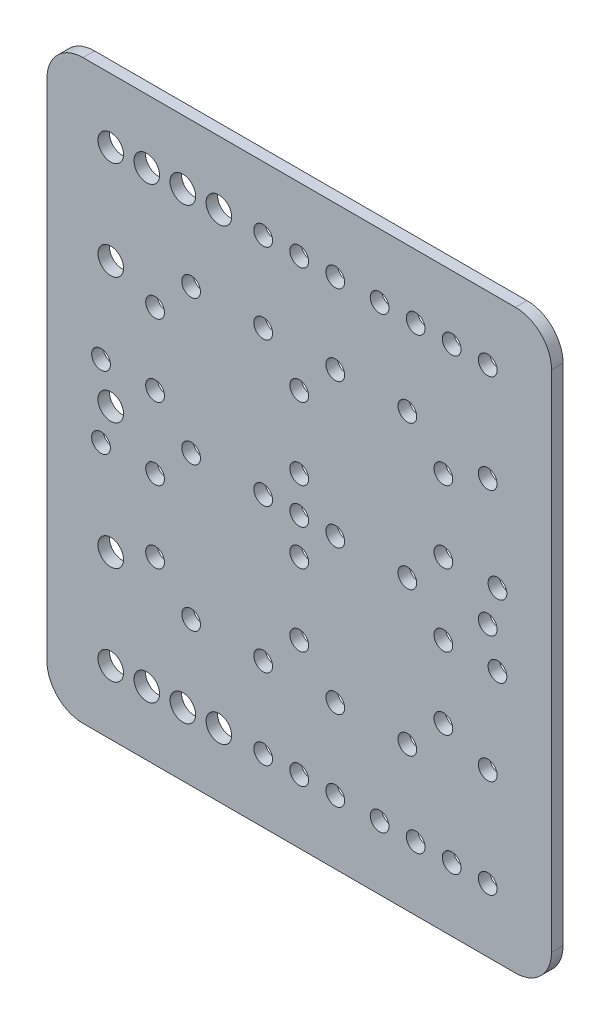
from build123d import *

# Parameters (mm, degrees)
SKETCH1_W           = 140
SKETCH1_H           = 160
SKETCH1_R           = 2.6
SKETCH1_R_2         = 3.55
BOSS_EXTRUDE1_DEPTH = 3.2
FILLET1_R           = 10


with BuildPart() as part:
    # Sketch1 → Boss-Extrude1 (new body)
    with BuildSketch(Plane.XY):
        Rectangle(SKETCH1_W, SKETCH1_H)
        Circle(SKETCH1_R, mode=Mode.SUBTRACT)
        with Locations((10, 0)):
            Circle(SKETCH1_R, mode=Mode.SUBTRACT)
        with Locations((-40, 10)):
            Circle(SKETCH1_R, mode=Mode.SUBTRACT)
        with Locations((30, 0)):
            Circle(SKETCH1_R, mode=Mode.SUBTRACT)
        with Locations((-10, 0)):
            Circle(SKETCH1_R, mode=Mode.SUBTRACT)
        with Locations((40, 10)):
            Circle(SKETCH1_R, mode=Mode.SUBTRACT)
        with Locations((-30, 0)):
            Circle(SKETCH1_R, mode=Mode.SUBTRACT)
        with Locations((0, 10)):
            Circle(SKETCH1_R, mode=Mode.SUBTRACT)
        with Locations((-52.3, 35)):
            Circle(SKETCH1_R_2, mode=Mode.SUBTRACT)
        with Locations((52.3, 35)):
            Circle(SKETCH1_R, mode=Mode.SUBTRACT)
        with Locations((22.3, 62.3)):
            Circle(SKETCH1_R, mode=Mode.SUBTRACT)
        with Locations((0, 30)):
            Circle(SKETCH1_R, mode=Mode.SUBTRACT)
        with Locations((-10, 40)):
            Circle(SKETCH1_R, mode=Mode.SUBTRACT)
        with Locations((52.3, 0)):
            Circle(SKETCH1_R, mode=Mode.SUBTRACT)
        with Locations((-52.3, 0)):
            Circle(SKETCH1_R_2, mode=Mode.SUBTRACT)
        with Locations((-30, 40)):
            Circle(SKETCH1_R, mode=Mode.SUBTRACT)
        with Locations((-52.3, 62.3)):
            Circle(SKETCH1_R_2, mode=Mode.SUBTRACT)
        with Locations((-40, 30)):
            Circle(SKETCH1_R, mode=Mode.SUBTRACT)
        with Locations((40, 30)):
            Circle(SKETCH1_R, mode=Mode.SUBTRACT)
        with Locations((30, 40)):
            Circle(SKETCH1_R, mode=Mode.SUBTRACT)
        with Locations((52.3, 62.3)):
            Circle(SKETCH1_R, mode=Mode.SUBTRACT)
        with Locations((10, 40)):
            Circle(SKETCH1_R, mode=Mode.SUBTRACT)
        with Locations((-42.3, 62.3)):
            Circle(SKETCH1_R_2, mode=Mode.SUBTRACT)
        with Locations((-32.3, 62.3)):
            Circle(SKETCH1_R_2, mode=Mode.SUBTRACT)
        with Locations((-22.3, -62.3)):
            Circle(SKETCH1_R_2, mode=Mode.SUBTRACT)
        with Locations((55, -10)):
            Circle(SKETCH1_R, mode=Mode.SUBTRACT)
        with Locations((42.3, 62.3)):
            Circle(SKETCH1_R, mode=Mode.SUBTRACT)
        with Locations((-55, -10)):
            Circle(SKETCH1_R, mode=Mode.SUBTRACT)
        with Locations((-10, -62.3)):
            Circle(SKETCH1_R, mode=Mode.SUBTRACT)
        with Locations((0, 62.3)):
            Circle(SKETCH1_R, mode=Mode.SUBTRACT)
        with Locations((10, 62.3)):
            Circle(SKETCH1_R, mode=Mode.SUBTRACT)
        with Locations((-10, 62.3)):
            Circle(SKETCH1_R, mode=Mode.SUBTRACT)
        with Locations((10, -62.3)):
            Circle(SKETCH1_R, mode=Mode.SUBTRACT)
        with Locations((0, -62.3)):
            Circle(SKETCH1_R, mode=Mode.SUBTRACT)
        with Locations((32.3, -62.3)):
            Circle(SKETCH1_R, mode=Mode.SUBTRACT)
        with Locations((42.3, -62.3)):
            Circle(SKETCH1_R, mode=Mode.SUBTRACT)
        with Locations((-55, 10)):
            Circle(SKETCH1_R, mode=Mode.SUBTRACT)
        with Locations((55, 10)):
            Circle(SKETCH1_R, mode=Mode.SUBTRACT)
        with Locations((-32.3, -62.3)):
            Circle(SKETCH1_R_2, mode=Mode.SUBTRACT)
        with Locations((-42.3, -62.3)):
            Circle(SKETCH1_R_2, mode=Mode.SUBTRACT)
        with Locations((10, -40)):
            Circle(SKETCH1_R, mode=Mode.SUBTRACT)
        with Locations((52.3, -62.3)):
            Circle(SKETCH1_R, mode=Mode.SUBTRACT)
        with Locations((30, -40)):
            Circle(SKETCH1_R, mode=Mode.SUBTRACT)
        with Locations((40, -30)):
            Circle(SKETCH1_R, mode=Mode.SUBTRACT)
        with Locations((-40, -30)):
            Circle(SKETCH1_R, mode=Mode.SUBTRACT)
        with Locations((-52.3, -62.3)):
            Circle(SKETCH1_R_2, mode=Mode.SUBTRACT)
        with Locations((-30, -40)):
            Circle(SKETCH1_R, mode=Mode.SUBTRACT)
        with Locations((-10, -40)):
            Circle(SKETCH1_R, mode=Mode.SUBTRACT)
        with Locations((-22.3, 62.3)):
            Circle(SKETCH1_R_2, mode=Mode.SUBTRACT)
        with Locations((0, -30)):
            Circle(SKETCH1_R, mode=Mode.SUBTRACT)
        with Locations((32.3, 62.3)):
            Circle(SKETCH1_R, mode=Mode.SUBTRACT)
        with Locations((22.3, -62.3)):
            Circle(SKETCH1_R, mode=Mode.SUBTRACT)
        with Locations((52.3, -35)):
            Circle(SKETCH1_R, mode=Mode.SUBTRACT)
        with Locations((-52.3, -35)):
            Circle(SKETCH1_R_2, mode=Mode.SUBTRACT)
        with Locations((0, -10)):
            Circle(SKETCH1_R, mode=Mode.SUBTRACT)
        with Locations((40, -10)):
            Circle(SKETCH1_R, mode=Mode.SUBTRACT)
        with Locations((-40, -10)):
            Circle(SKETCH1_R, mode=Mode.SUBTRACT)
    extrude(amount=-BOSS_EXTRUDE1_DEPTH)

    # Fillet1
    fillet1_edges = [part.edges().sort_by_distance(p)[0] for p in [
        (70, -80, -1.6),
        (-70, -80, -1.6),
        (-70, 80, -1.6),
        (70, 80, -1.6),
    ]]
    fillet(fillet1_edges, radius=FILLET1_R)


solid = part.part
